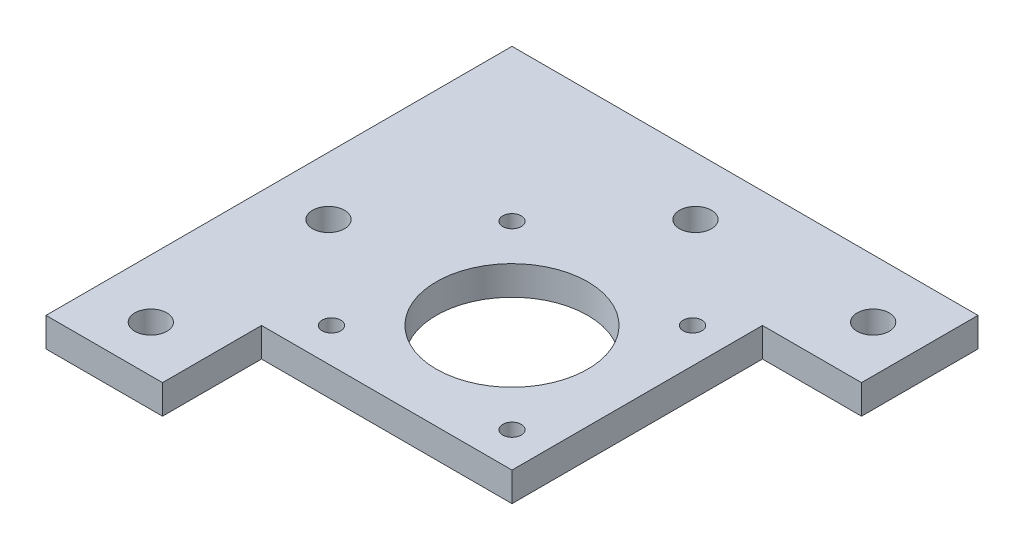
from build123d import *

# Parameters (mm, degrees)
SKETCH2_R           = 1.6
SKETCH2_R_2         = 13
SKETCH2_R_3         = 2.75
BOSS_EXTRUDE1_DEPTH = 5


with BuildPart() as part:
    # Sketch2 → Boss-Extrude1 (new body)
    with BuildSketch(Plane(origin=(0, 0, 0), x_dir=(1, 0, 0), z_dir=(0, 1, 0))):
        Polygon((0, 0), (20, 0), (20, 17), (63, 17), (63, 60), (80, 60), (80, 80), (0, 80), align=None)
        with Locations((57, 23)):
            Circle(SKETCH2_R, mode=Mode.SUBTRACT)
        with Locations((57, 54)):
            Circle(SKETCH2_R, mode=Mode.SUBTRACT)
        with Locations((26, 23)):
            Circle(SKETCH2_R, mode=Mode.SUBTRACT)
        with Locations((26, 54)):
            Circle(SKETCH2_R, mode=Mode.SUBTRACT)
        with Locations((41.5, 38.5)):
            Circle(SKETCH2_R_2, mode=Mode.SUBTRACT)
        with Locations((10, 8)):
            Circle(SKETCH2_R_3, mode=Mode.SUBTRACT)
        with Locations((72, 70)):
            Circle(SKETCH2_R_3, mode=Mode.SUBTRACT)
        with Locations((41.5, 70)):
            Circle(SKETCH2_R_3, mode=Mode.SUBTRACT)
        with Locations((10, 38.5)):
            Circle(SKETCH2_R_3, mode=Mode.SUBTRACT)
    extrude(amount=BOSS_EXTRUDE1_DEPTH)


solid = part.part
